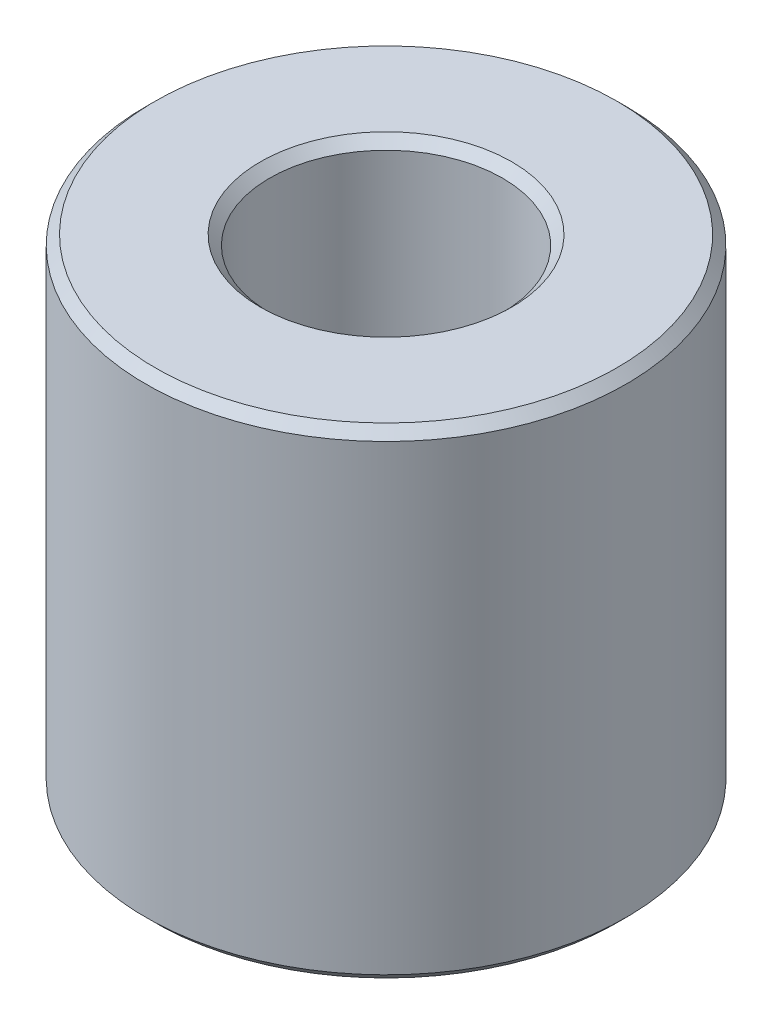
from build123d import *


with BuildPart() as part:
    # Sketch1 → Revolve1 (revolve)
    with BuildSketch(Plane.XY, mode=Mode.PRIVATE) as revolve1_sk:
        Polygon((6.246, 13), (6.5, 12.746), (6.5, 0.254), (6.246, 0), (3.404, 0), (3.15, 0.254), (3.15, 12.746), (3.404, 13), align=None)
    revolve(revolve1_sk.sketch.rotate(Axis((0, 0, 0), (0, 1, 0)), 90), axis=Axis((0, 0, 0), (0, 1, 0)))  # turned: the seam where the file's is


solid = part.part
